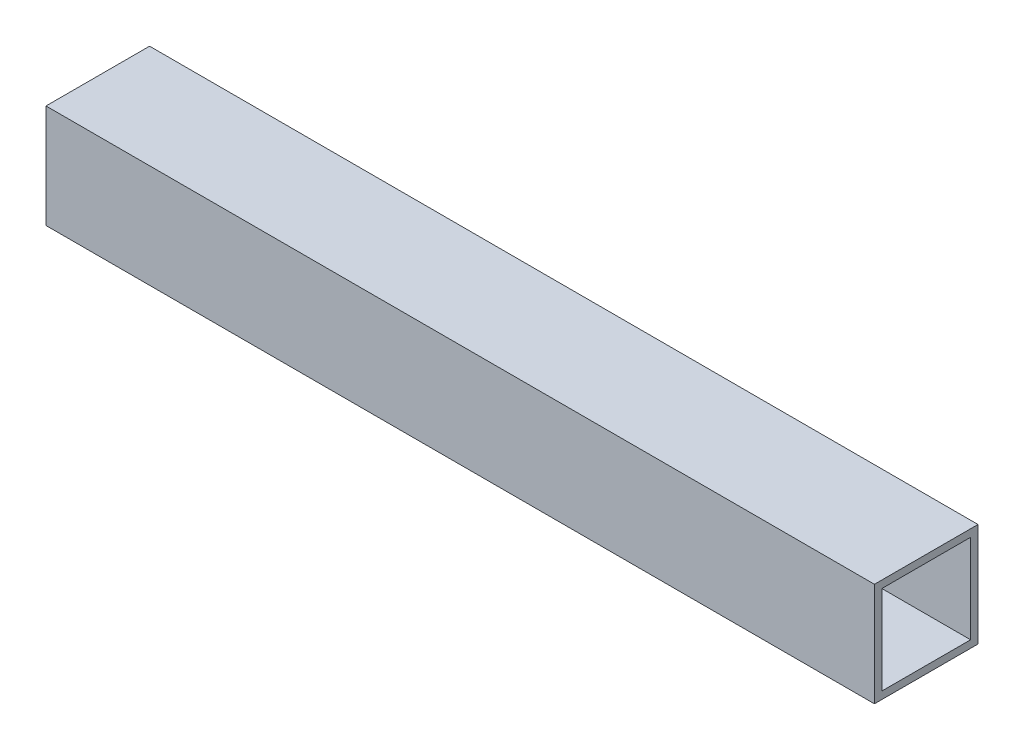
from build123d import *

# Parameters (mm, degrees)
SKETCH1_W           = 44.45
SKETCH1_H           = 44.45
SKETCH1_W_2         = 38.1
SKETCH1_H_2         = 38.1
BOSS_EXTRUDE1_DEPTH = 177.8


with BuildPart() as part:
    # Sketch1 → Boss-Extrude1 (new body, symmetric)
    with BuildSketch(Plane(origin=(0, 0, 0), x_dir=(0, 0, -1), z_dir=(1, 0, 0))):
        with Locations((22.225, 22.225)):
            Rectangle(SKETCH1_W, SKETCH1_H)
        with Locations((22.225, 22.225)):
            Rectangle(SKETCH1_W_2, SKETCH1_H_2, mode=Mode.SUBTRACT)
    extrude(amount=BOSS_EXTRUDE1_DEPTH, both=True)


solid = part.part
